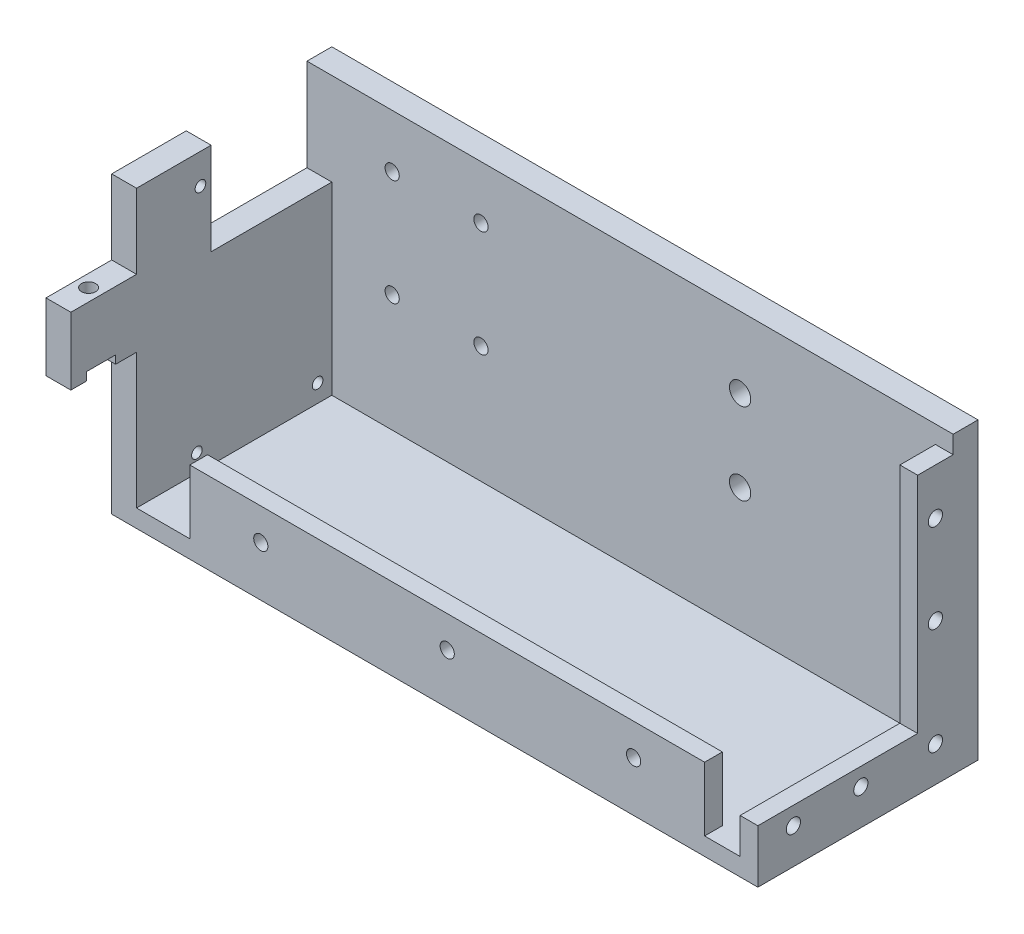
from build123d import *

# Parameters (mm, degrees)
SKETCH1_W           = 182
SKETCH1_H           = 62
BOSS_EXTRUDE1_DEPTH = 5
SKETCH2_W           = 145
SKETCH2_H           = 5
BOSS_EXTRUDE2_DEPTH = 18
SKETCH3_R           = 2
CUT_EXTRUDE1_DEPTH  = 18
SKETCH4_W           = 7
SKETCH4_H           = 62
BOSS_EXTRUDE3_DEPTH = 78
SKETCH5_W           = 175
SKETCH5_H           = 7
BOSS_EXTRUDE4_DEPTH = 78
SKETCH6_W           = 7
SKETCH6_H           = 19
BOSS_EXTRUDE5_DEPTH = 18.5
SKETCH7_R           = 2
CUT_EXTRUDE2_DEPTH  = 18
SKETCH8_W           = 7
SKETCH8_H           = 8.2
CUT_EXTRUDE3_DEPTH  = 2.3
SKETCH11_R          = 1.5
SKETCH11_W          = 34
SKETCH11_H          = 26
CUT_EXTRUDE5_DEPTH  = 10
SKETCH12_W          = 5
SKETCH12_H          = 55
BOSS_EXTRUDE6_DEPTH = 10
SKETCH13_W          = 5
SKETCH13_H          = 10
BOSS_EXTRUDE7_DEPTH = 63
SKETCH15_R          = 2
CUT_EXTRUDE6_DEPTH  = 63
SKETCH16_R          = 3
CUT_EXTRUDE7_DEPTH  = 10
SKETCH17_R          = 2
CUT_EXTRUDE8_DEPTH  = 10
SKETCH18_R          = 1.5
CUT_EXTRUDE9_DEPTH  = 10


with BuildPart() as part:
    # Sketch1 → Boss-Extrude1 (new body)
    with BuildSketch(Plane(origin=(0, 0, 0), x_dir=(1, 0, 0), z_dir=(0, 1, 0))):
        with Locations((46.151515152, -7.666666667)):
            Rectangle(SKETCH1_W, SKETCH1_H)
    extrude(amount=BOSS_EXTRUDE1_DEPTH)

    # Sketch2 → Boss-Extrude2 (add)
    with BuildSketch(Plane(origin=(0, 5, 0), x_dir=(1, 0, 0), z_dir=(0, 1, 0))):
        with Locations((49.651515152, -36.166666667)):
            Rectangle(SKETCH2_W, SKETCH2_H)
    extrude(amount=BOSS_EXTRUDE2_DEPTH)

    # Sketch3 → Cut-Extrude1 (cut)
    with BuildSketch(Plane(origin=(0, 0, 33.666666667), x_dir=(-1, 0, 0), z_dir=(0, 0, -1))):
        with Locations((-102.151515152, 14.1)):
            Circle(SKETCH3_R)
        with Locations((-49.651515152, 14.1)):
            Circle(SKETCH3_R)
        with Locations((2.848484848, 14.1)):
            Circle(SKETCH3_R)
    extrude(amount=-CUT_EXTRUDE1_DEPTH, mode=Mode.SUBTRACT)

    # Sketch4 → Boss-Extrude3 (add)
    with BuildSketch(Plane(origin=(0, 5, 0), x_dir=(1, 0, 0), z_dir=(0, 1, 0))):
        with Locations((-41.348484848, -7.666666667)):
            Rectangle(SKETCH4_W, SKETCH4_H)
    extrude(amount=BOSS_EXTRUDE3_DEPTH)

    # Sketch5 → Boss-Extrude4 (add)
    with BuildSketch(Plane(origin=(0, 5, 0), x_dir=(1, 0, 0), z_dir=(0, 1, 0))):
        with Locations((49.651515152, 19.833333333)):
            Rectangle(SKETCH5_W, SKETCH5_H)
    extrude(amount=BOSS_EXTRUDE4_DEPTH)

    # Sketch6 → Boss-Extrude5 (add)
    with BuildSketch(Plane.XY.offset(38.666666667)):
        with Locations((-41.348484848, 52.5)):
            Rectangle(SKETCH6_W, SKETCH6_H)
    extrude(amount=BOSS_EXTRUDE5_DEPTH)

    # Sketch7 → Cut-Extrude2 (cut)
    with BuildSketch(Plane(origin=(0, 62, 0), x_dir=(1, 0, 0), z_dir=(0, 1, 0))):
        with Locations((-41.348484848, -48.666666667)):
            Circle(SKETCH7_R)
    extrude(amount=-CUT_EXTRUDE2_DEPTH, mode=Mode.SUBTRACT)

    # Sketch8 → Cut-Extrude3 (cut)
    with BuildSketch(Plane.XZ.offset(-43)):
        with Locations((-41.348484848, 48.666666667)):
            Rectangle(SKETCH8_W, SKETCH8_H)
    extrude(amount=-CUT_EXTRUDE3_DEPTH, mode=Mode.SUBTRACT)

    # Sketch11 → Cut-Extrude5 (cut)
    with BuildSketch(Plane(origin=(-37.848484848, 0, 0), x_dir=(0, 0, -1), z_dir=(1, 0, 0))):
        with Locations((-20.666666667, 74.5)):
            Circle(SKETCH11_R)
        with Locations((-0.666666667, 70)):
            Rectangle(SKETCH11_W, SKETCH11_H)
    extrude(amount=-CUT_EXTRUDE5_DEPTH, mode=Mode.SUBTRACT)

    # Sketch12 → Boss-Extrude6 (add)
    with BuildSketch(Plane(origin=(0, 5, 0), x_dir=(1, 0, 0), z_dir=(0, 1, 0))):
        with Locations((134.651515152, -11.166666667)):
            Rectangle(SKETCH12_W, SKETCH12_H)
    extrude(amount=BOSS_EXTRUDE6_DEPTH)

    # Sketch13 → Boss-Extrude7 (add)
    with BuildSketch(Plane(origin=(0, 15, 0), x_dir=(1, 0, 0), z_dir=(0, 1, 0))):
        with Locations((134.651515152, 11.333333333)):
            Rectangle(SKETCH13_W, SKETCH13_H)
    extrude(amount=BOSS_EXTRUDE7_DEPTH)

    # Sketch15 → Cut-Extrude6 (cut)
    with BuildSketch(Plane(origin=(137.151515152, 0, 0), x_dir=(0, 0, -1), z_dir=(1, 0, 0))):
        with Locations((11.333333333, 65)):
            Circle(SKETCH15_R)
        with Locations((11.333333333, 40)):
            Circle(SKETCH15_R)
        with Locations((11.333333333, 10)):
            Circle(SKETCH15_R)
        with Locations((-28.666666667, 10)):
            Circle(SKETCH15_R)
        with Locations((-9.666666667, 10)):
            Circle(SKETCH15_R)
    extrude(amount=-CUT_EXTRUDE6_DEPTH, mode=Mode.SUBTRACT)

    # Sketch16 → Cut-Extrude7 (cut)
    with BuildSketch(Plane(origin=(0, 0, -23.333333333), x_dir=(-1, 0, 0), z_dir=(0, 0, -1))):
        with Locations((-77.151515152, 40)):
            Circle(SKETCH16_R)
        with Locations((-77.151515152, 63)):
            Circle(SKETCH16_R)
    extrude(amount=-CUT_EXTRUDE7_DEPTH, mode=Mode.SUBTRACT)

    # Sketch17 → Cut-Extrude8 (cut)
    with BuildSketch(Plane(origin=(0, 0, -23.333333333), x_dir=(-1, 0, 0), z_dir=(0, 0, -1))):
        with Locations((20.848484848, 68)):
            Circle(SKETCH17_R)
        with Locations((20.848484848, 38)):
            Circle(SKETCH17_R)
        with Locations((-4.151515152, 38)):
            Circle(SKETCH17_R)
        with Locations((-4.151515152, 68)):
            Circle(SKETCH17_R)
    extrude(amount=-CUT_EXTRUDE8_DEPTH, mode=Mode.SUBTRACT)

    # Sketch18 → Cut-Extrude9 (cut)
    with BuildSketch(Plane(origin=(-37.848484848, 0, 0), x_dir=(0, 0, -1), z_dir=(1, 0, 0))):
        with Locations((12.333333333, 10)):
            Circle(SKETCH18_R)
        with Locations((-21.666666667, 10)):
            Circle(SKETCH18_R)
    extrude(amount=-CUT_EXTRUDE9_DEPTH, mode=Mode.SUBTRACT)


solid = part.part
